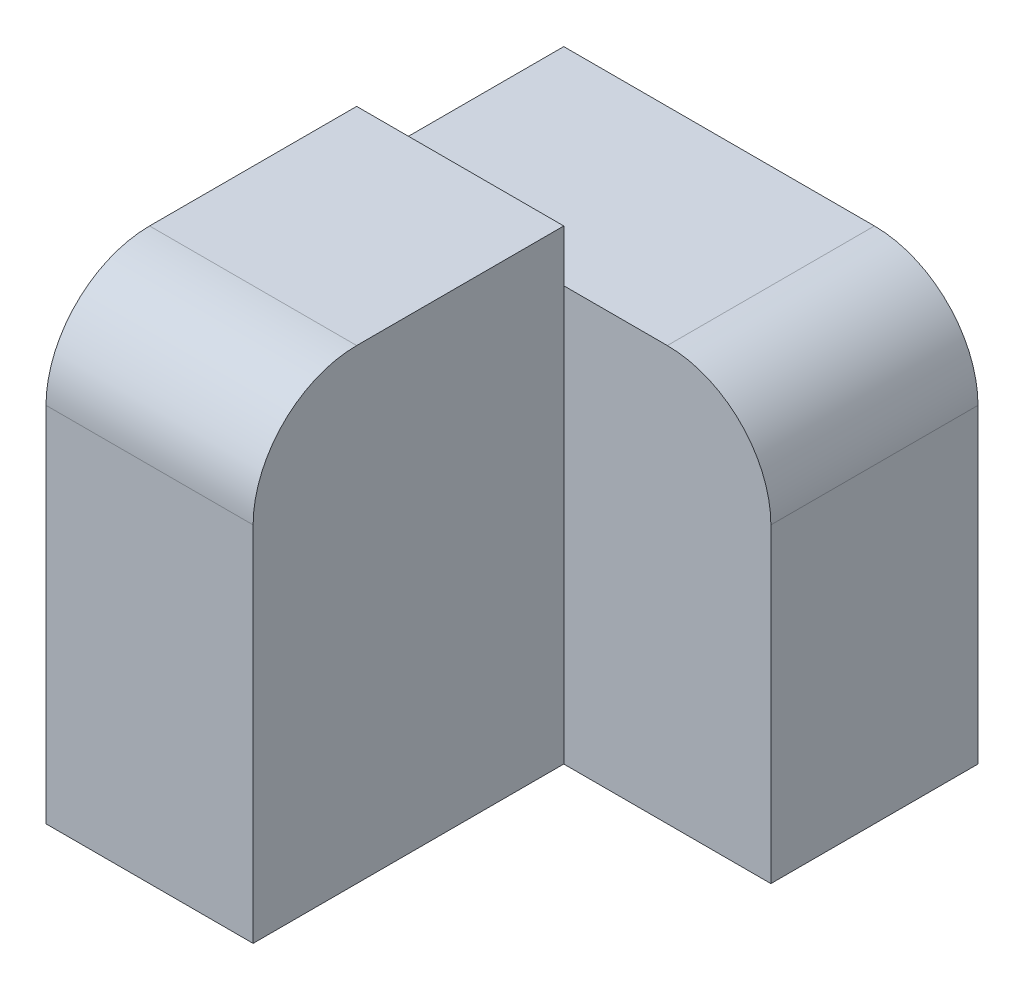
from build123d import *

# Parameters (mm, degrees)
SKETCH1_W           = 20
SKETCH1_H           = 45
BOSS_EXTRUDE1_DEPTH = 30
SKETCH2_W           = 40
SKETCH2_H           = 40
BOSS_EXTRUDE2_DEPTH = 20
FILLET1_R           = 10


with BuildPart() as part:
    # Sketch1 → Boss-Extrude1 (new body)
    with BuildSketch(Plane.XY):
        with Locations((-20, -22.5)):
            Rectangle(SKETCH1_W, SKETCH1_H)
    extrude(amount=BOSS_EXTRUDE1_DEPTH)

    # Sketch2 → Boss-Extrude2 (add)
    with BuildSketch(Plane.XY):
        with Locations((-10, -25)):
            Rectangle(SKETCH2_W, SKETCH2_H)
    extrude(amount=-BOSS_EXTRUDE2_DEPTH)

    # Fillet1
    fillet1_edges = [part.edges().sort_by_distance(p)[0] for p in [
        (10, -5, -10),
        (-20, 0, 30),
    ]]
    fillet(fillet1_edges, radius=FILLET1_R)


solid = part.part
